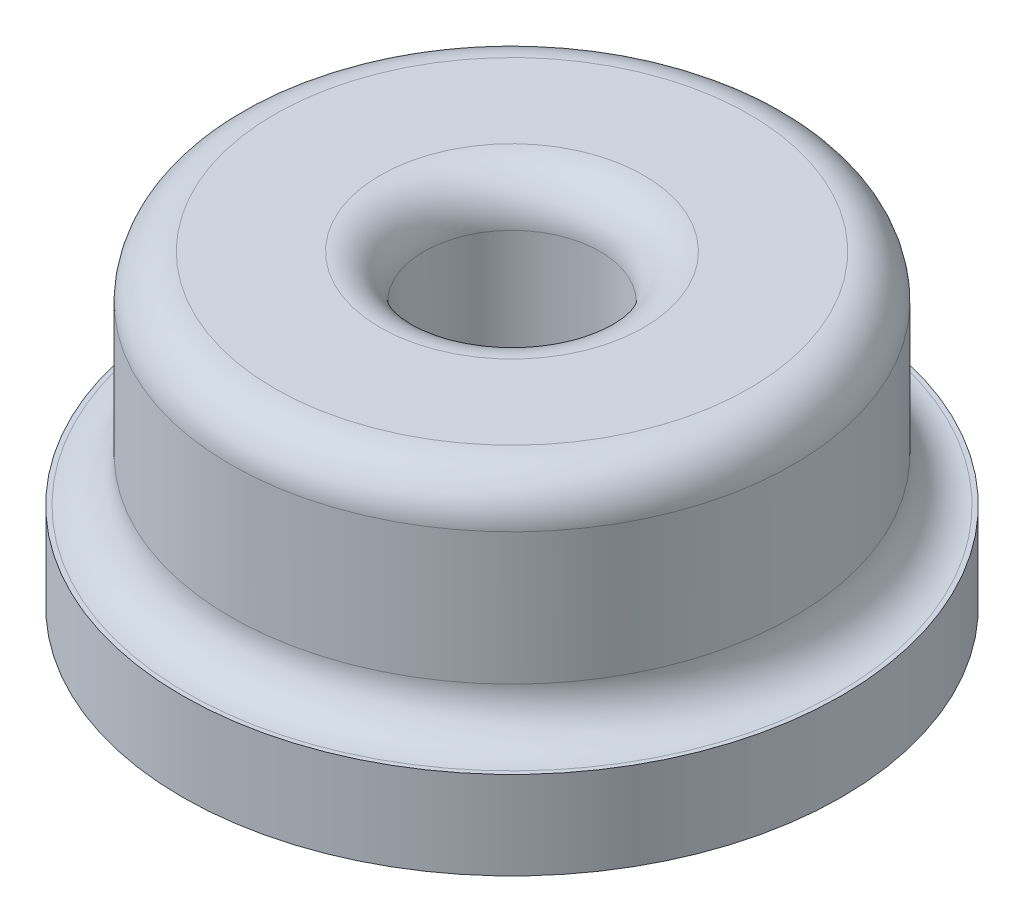
from build123d import *

# Parameters (mm, degrees)
SKETCH_1_R          = 6.4
EXTRUDE_1_DEPTH     = 5
SKETCH_3_R          = 7.5
EXTRUDE_2_DEPTH     = 2
SKETCH_2_R          = 2
CUT_EXTRUDE_1_DEPTH = 8
FILLET_1_R          = 1
FILLET_2_R          = 1
FILLET_3_R          = 1


with BuildPart() as part:
    # 草图1 → 凸台-拉伸1 (new body)
    with BuildSketch(Plane(origin=(0, 0, 0), x_dir=(1, 0, 0), z_dir=(0, 1, 0))):
        Circle(SKETCH_1_R)
    extrude(amount=EXTRUDE_1_DEPTH)

    # 草图3 → 凸台-拉伸2 (add)
    with BuildSketch(Plane.XZ):
        Circle(SKETCH_3_R)
    extrude(amount=EXTRUDE_2_DEPTH)

    # 草图2 → 切除-拉伸1 (cut, through all)
    with BuildSketch(Plane(origin=(0, 5, 0), x_dir=(1, 0, 0), z_dir=(0, 1, 0))):
        Circle(SKETCH_2_R)
    extrude(amount=-CUT_EXTRUDE_1_DEPTH, mode=Mode.SUBTRACT)

    # 圆角1
    fillet_1_edges = [part.edges().sort_by_distance(p)[0] for p in [
        (-2, 5, 0),
        (-6.4, 5, 0),
    ]]
    fillet(fillet_1_edges, radius=FILLET_1_R)

    # 圆角2
    fillet_2_edges = [part.edges().sort_by_distance(p)[0] for p in [
        (-6.4, 0, 0),
    ]]
    fillet(fillet_2_edges, radius=FILLET_2_R)

    # 圆角3
    fillet_3_edges = [part.edges().sort_by_distance(p)[0] for p in [
        (-2, -2, 0),
    ]]
    fillet(fillet_3_edges, radius=FILLET_3_R)


solid = part.part
